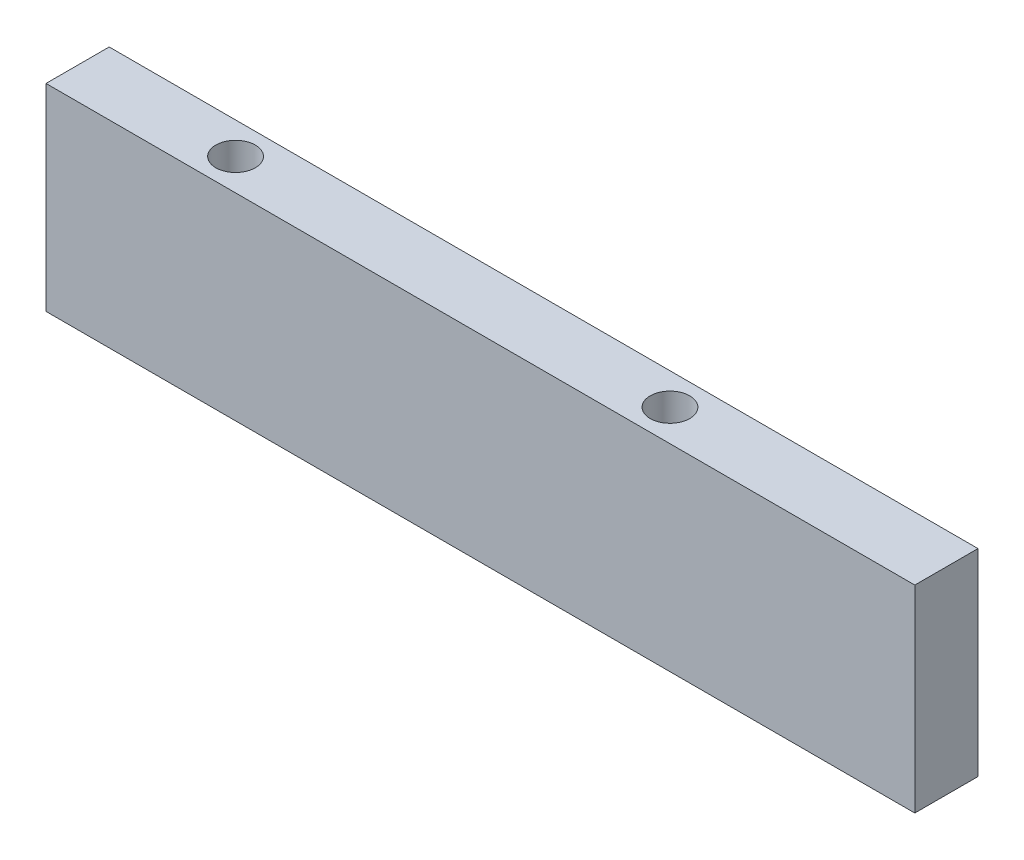
from build123d import *

# Parameters (mm, degrees)
SKETCH1_W           = 110
SKETCH1_H           = 8
BOSS_EXTRUDE1_DEPTH = 25
SKETCH2_R           = 2.5
CUT_EXTRUDE1_DEPTH  = 26


with BuildPart() as part:
    # Sketch1 → Boss-Extrude1 (new body)
    with BuildSketch(Plane(origin=(0, 0, 0), x_dir=(1, 0, 0), z_dir=(0, 1, 0))):
        with Locations((55, 4)):
            Rectangle(SKETCH1_W, SKETCH1_H)
    extrude(amount=BOSS_EXTRUDE1_DEPTH)

    # Sketch2 → Cut-Extrude1 (cut, through all)
    with BuildSketch(Plane(origin=(0, 25, 0), x_dir=(1, 0, 0), z_dir=(0, 1, 0))):
        with Locations((20, 4)):
            Circle(SKETCH2_R)
        with Locations((75, 4)):
            Circle(SKETCH2_R)
    extrude(amount=-CUT_EXTRUDE1_DEPTH, mode=Mode.SUBTRACT)


solid = part.part
